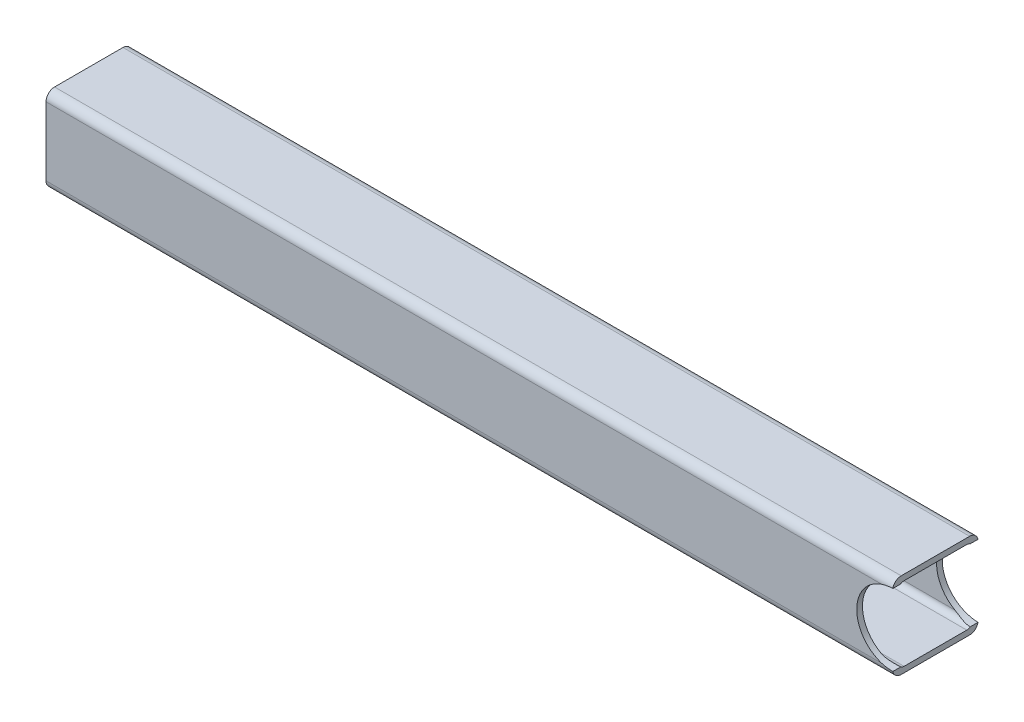
from build123d import *

# Parameters (mm, degrees)
EXTRUDE_1_DEPTH     = 297.016771
SKETCH_2_R          = 12.6
CUT_EXTRUDE_1_DEPTH = 31


with BuildPart() as part:
    # Эскиз1 → Бобышка-Вытянуть1 (new body)
    with BuildSketch(Plane(origin=(0, 0, 0), x_dir=(0, 0, -1), z_dir=(1, 0, 0))):
        with BuildLine():
            Line((-12, 15), (12, 15))
            ThreePointArc((12, 15), (14.121320344, 14.121320344), (15, 12))
            Line((15, 12), (15, -12))
            ThreePointArc((15, -12), (14.121320344, -14.121320344), (12, -15))
            Line((12, -15), (-12, -15))
            ThreePointArc((-12, -15), (-14.121320344, -14.121320344), (-15, -12))
            Line((-15, -12), (-15, 12))
            ThreePointArc((-15, 12), (-14.121320344, 14.121320344), (-12, 15))
        make_face()
        with BuildLine():
            Line((-11, 13), (11, 13))
            ThreePointArc((11, 13), (12.414213562, 12.414213562), (13, 11))
            Line((13, 11), (13, -11))
            ThreePointArc((13, -11), (12.414213562, -12.414213562), (11, -13))
            Line((11, -13), (-11, -13))
            ThreePointArc((-11, -13), (-12.414213562, -12.414213562), (-13, -11))
            Line((-13, -11), (-13, 11))
            ThreePointArc((-13, 11), (-12.414213562, 12.414213562), (-11, 13))
        make_face(mode=Mode.SUBTRACT)
    extrude(amount=-EXTRUDE_1_DEPTH)

    # Эскиз2 → Вырез-Вытянуть1 (cut, through all)
    with BuildSketch(Plane.XY.offset(15)):
        Circle(SKETCH_2_R)
    extrude(amount=-CUT_EXTRUDE_1_DEPTH, mode=Mode.SUBTRACT)


solid = part.part
